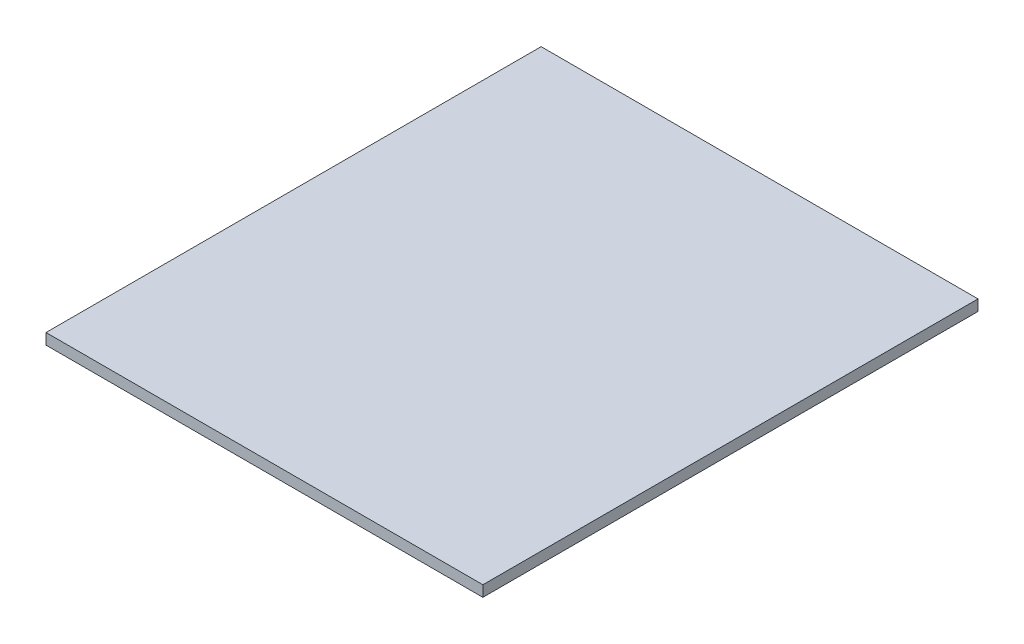
from build123d import *

# Parameters (mm, degrees)
SKETCH1_W           = 120
SKETCH1_H           = 136
BOSS_EXTRUDE1_DEPTH = 3


with BuildPart() as part:
    # Sketch1 → Boss-Extrude1 (new body)
    with BuildSketch(Plane(origin=(0, 0, 0), x_dir=(1, 0, 0), z_dir=(0, 1, 0))):
        with Locations((60, 68)):
            Rectangle(SKETCH1_W, SKETCH1_H)
    extrude(amount=BOSS_EXTRUDE1_DEPTH)


solid = part.part
